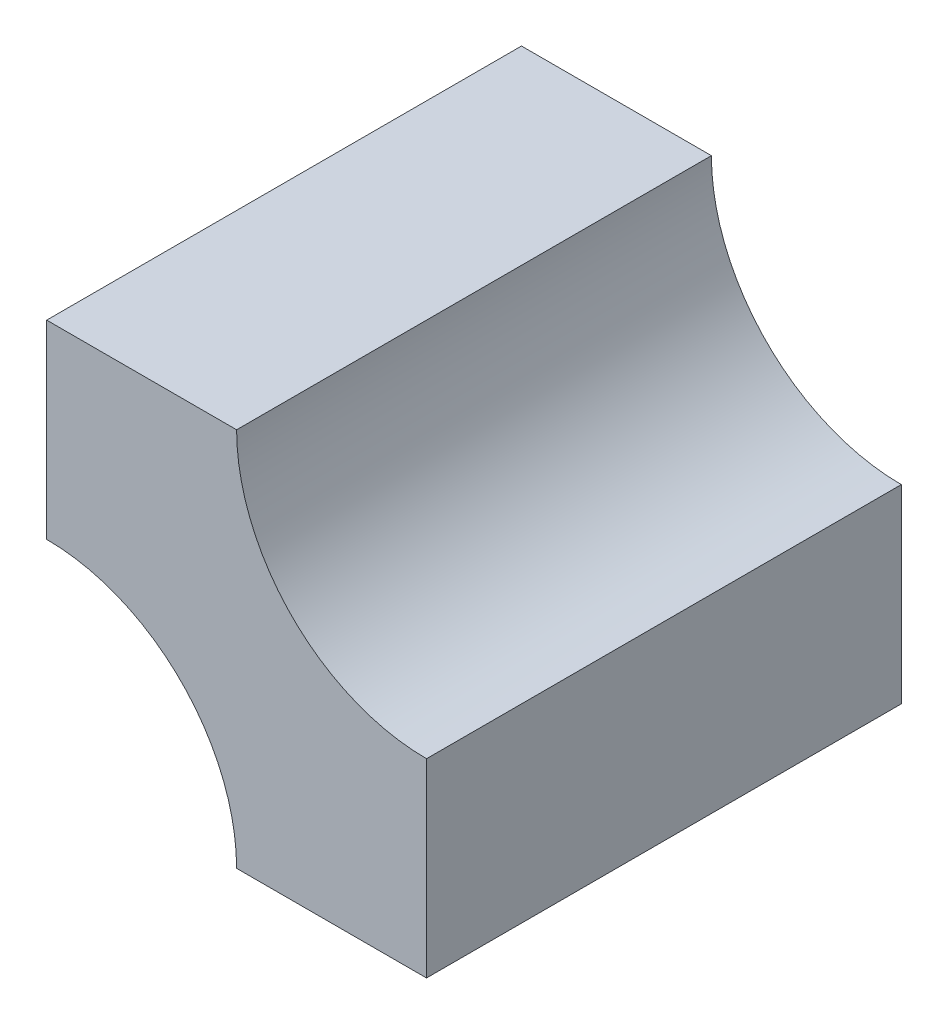
from build123d import *

# Parameters (mm, degrees)
BOSS_EXTRUDE1_DEPTH = 25


with BuildPart() as part:
    # Sketch1 → Boss-Extrude1 (new body)
    with BuildSketch(Plane.XY):
        with BuildLine():
            Line((-20, 10), (-20, 20))
            Line((-20, 20), (-10, 20))
            ThreePointArc((-10, 20), (-7.071067812, 12.928932188), (0, 10))
            Line((0, 10), (0, 0))
            Line((0, 0), (-10, 0))
            ThreePointArc((-10, 0), (-12.928932188, 7.071067812), (-20, 10))
        make_face()
    extrude(amount=BOSS_EXTRUDE1_DEPTH)


solid = part.part
